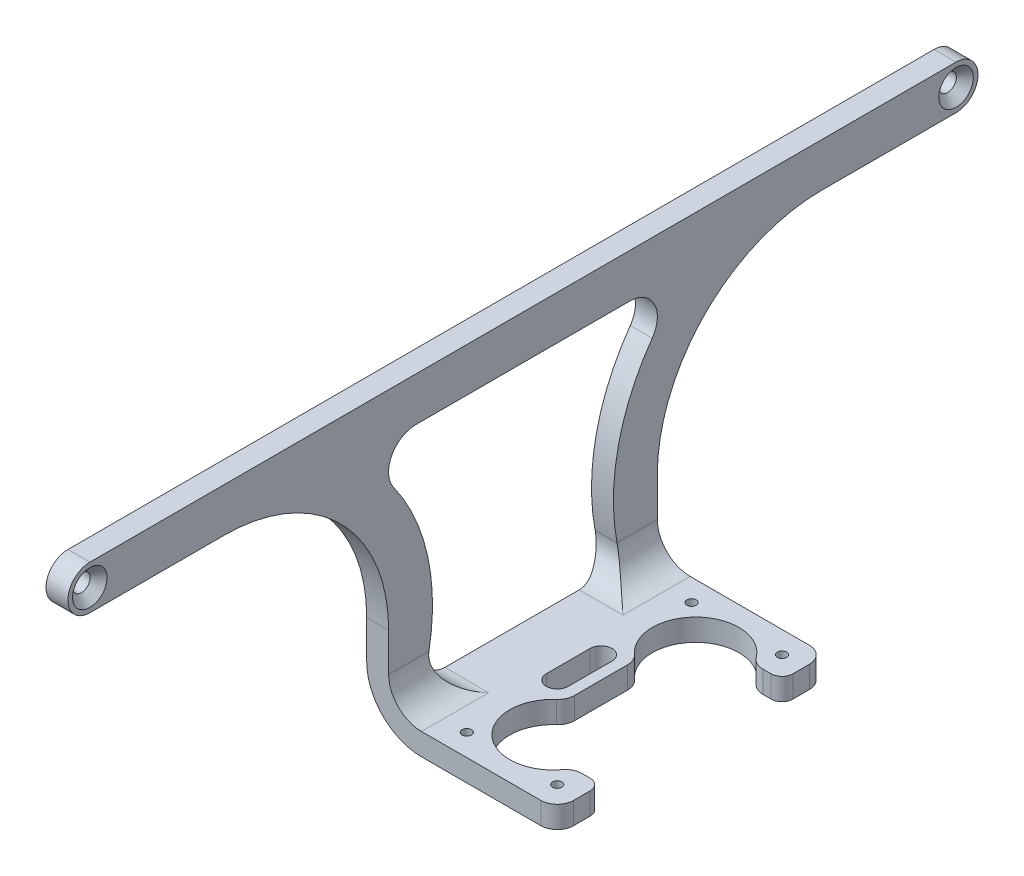
from build123d import *

# Parameters (mm, degrees)
BOSS_EXTRU_1_DEPTH                             = 166
FRAISAGE_POUR_VIS_T_TE_FRAIS_E_M31_D           = 3.2
FRAISAGE_POUR_VIS_T_TE_FRAIS_E_M31_DEPTH       = 4
FRAISAGE_POUR_VIS_T_TE_FRAIS_E_M31_CSINK_D     = 6.3
FRAISAGE_POUR_VIS_T_TE_FRAIS_E_M31_CSINK_ANGLE = 90
D_GAGEMENT_M1_61_D                             = 1.7
D_GAGEMENT_M1_61_DEPTH                         = 4
ENL_V_MAT_EXTRU_1_DEPTH                        = 4
ENL_V_MAT_EXTRU_2_DEPTH                        = 31.75
ENL_V_MAT_EXTRU_2_DEPTH_BACK                   = 5


with BuildPart() as part:
    # Esquisse1 → Boss.-Extru.1 (new body)
    with BuildSketch(Plane.XY):
        with BuildLine():
            Line((0, 0), (-25, 0))
            ThreePointArc((-25, 0), (-32.071067812, 2.928932188), (-35, 10))
            Line((-35, 10), (-35, 55))
            Line((-35, 55), (-31, 55))
            Line((-31, 55), (-31, 10))
            ThreePointArc((-31, 10), (-29.242640687, 5.757359313), (-25, 4))
            Line((-25, 4), (0, 4))
            Line((0, 4), (0, 0))
        make_face()
    extrude(amount=BOSS_EXTRU_1_DEPTH)

    # Fraisage pour vis à tête fraisée M31
    with Locations(Plane(origin=(-31, 0, 0), x_dir=(0, 0, 1), z_dir=(1, 0, 0))):
        with Locations((4, -51), (162, -51)):
            CounterSinkHole(FRAISAGE_POUR_VIS_T_TE_FRAIS_E_M31_D / 2, FRAISAGE_POUR_VIS_T_TE_FRAIS_E_M31_CSINK_D / 2, depth=FRAISAGE_POUR_VIS_T_TE_FRAIS_E_M31_DEPTH, counter_sink_angle=FRAISAGE_POUR_VIS_T_TE_FRAIS_E_M31_CSINK_ANGLE)

    # Dégagement M1.61
    with Locations(Plane(origin=(0, 0, 0), x_dir=(-1, 0, 0), z_dir=(0, -1, 0))):
        with Locations((20.75, -62.5), (20.75, -103.5), (4.25, -103.5), (4.25, -62.5)):
            Hole(D_GAGEMENT_M1_61_D / 2, depth=D_GAGEMENT_M1_61_DEPTH)

    # Esquisse6 → Enlèv. mat.-Extru.1 (cut)
    with BuildSketch(Plane.XZ):
        with BuildLine():
            Line((-35, 58.5), (-3.25, 58.5))
            ThreePointArc((-3.25, 58.5), (-1.128679656, 59.378679656), (-0.25, 61.5))
            Line((-0.25, 61.5), (-0.25, 64.5))
            ThreePointArc((-0.25, 64.5), (-0.835786438, 65.914213562), (-2.25, 66.5))
            Line((-2.25, 66.5), (-3.750142858, 66.5))
            ThreePointArc((-3.750142858, 66.5), (-5.097923909, 66.180202649), (-6.15836042, 65.288990826))
            ThreePointArc((-6.15836042, 65.288990826), (-17.832822404, 64.171534919), (-17.754587156, 75.899094322))
            ThreePointArc((-17.754587156, 75.899094322), (-17.012643745, 76.911706018), (-16.75, 78.139256723))
            Line((-16.75, 78.139256723), (-16.75, 87.860743277))
            ThreePointArc((-16.75, 87.860743277), (-17.012643745, 89.088293982), (-17.754587156, 90.100905678))
            ThreePointArc((-17.754587156, 90.100905678), (-17.832822404, 101.828465081), (-6.15836042, 100.711009174))
            ThreePointArc((-6.15836042, 100.711009174), (-5.097923909, 99.819797351), (-3.750142858, 99.5))
            Line((-3.750142858, 99.5), (-2.25, 99.5))
            ThreePointArc((-2.25, 99.5), (-0.835786438, 100.085786438), (-0.25, 101.5))
            Line((-0.25, 101.5), (-0.25, 104.5))
            ThreePointArc((-0.25, 104.5), (-1.128679656, 106.621320344), (-3.25, 107.5))
            Line((-3.25, 107.5), (-35, 107.5))
            Line((-35, 107.5), (-35, 166))
            Line((-35, 166), (0, 166))
            Line((0, 166), (0, 0))
            Line((0, 0), (-35, 0))
            Line((-35, 0), (-35, 58.5))
        make_face()
        with BuildLine():
            Line((-18.75, 87), (-18.75, 79))
            ThreePointArc((-18.75, 79), (-20.75, 77), (-22.75, 79))
            Line((-22.75, 79), (-22.75, 87))
            ThreePointArc((-22.75, 87), (-20.75, 89), (-18.75, 87))
        make_face()
    extrude(amount=-ENL_V_MAT_EXTRU_1_DEPTH, mode=Mode.SUBTRACT)

    # Esquisse7 → Enlèv. mat.-Extru.2 (cut, two sides)
    with BuildSketch(Plane(origin=(-31, 0, 0), x_dir=(0, 0, -1), z_dir=(1, 0, 0))) as enl_v_mat_extru_2_sk:
        with BuildLine():
            ThreePointArc((-4, 55), (-1.171572875, 53.828427125), (0, 51))
            Line((0, 51), (0, 55))
            Line((0, 55), (-4, 55))
        make_face()
        with BuildLine():
            Line((0, 4), (0, 51))
            ThreePointArc((0, 51), (-1.171572875, 48.171572875), (-4, 47))
            Line((-4, 47), (-28.5, 47))
            ThreePointArc((-28.5, 47), (-49.713203436, 38.213203436), (-58.5, 17))
            Line((-58.5, 17), (-58.5, 4))
            Line((-58.5, 4), (0, 4))
        make_face()
        with BuildLine():
            ThreePointArc((-162, 47), (-164.828427125, 48.171572875), (-166, 51))
            Line((-166, 51), (-166, 4))
            Line((-166, 4), (-107.5, 4))
            Line((-107.5, 4), (-107.5, 17))
            ThreePointArc((-107.5, 17), (-116.286796564, 38.213203436), (-137.5, 47))
            Line((-137.5, 47), (-162, 47))
        make_face()
        with BuildLine():
            Line((-166, 55), (-166, 51))
            ThreePointArc((-166, 51), (-164.828427125, 53.828427125), (-162, 55))
            Line((-162, 55), (-166, 55))
        make_face()
        with BuildLine():
            Line((-63.485711369, 47), (-102.514288631, 47))
            ThreePointArc((-102.514288631, 47), (-106.960347769, 44.287478555), (-106.582394604, 39.093023256))
            ThreePointArc((-106.582394604, 39.093023256), (-100.388347981, 25.168554611), (-100.163444343, 9.930232558))
            ThreePointArc((-100.163444343, 9.930232558), (-99.101139812, 5.810263552), (-95.250739651, 4))
            Line((-95.250739651, 4), (-70.749260349, 4))
            ThreePointArc((-70.749260349, 4), (-66.898860188, 5.810263552), (-65.836555657, 9.930232558))
            ThreePointArc((-65.836555657, 9.930232558), (-65.611652019, 25.168554611), (-59.417605396, 39.093023256))
            ThreePointArc((-59.417605396, 39.093023256), (-59.039652231, 44.287478555), (-63.485711369, 47))
        make_face()
    extrude(amount=ENL_V_MAT_EXTRU_2_DEPTH, mode=Mode.SUBTRACT)
    extrude(enl_v_mat_extru_2_sk.sketch, amount=-ENL_V_MAT_EXTRU_2_DEPTH_BACK, mode=Mode.SUBTRACT)


solid = part.part
